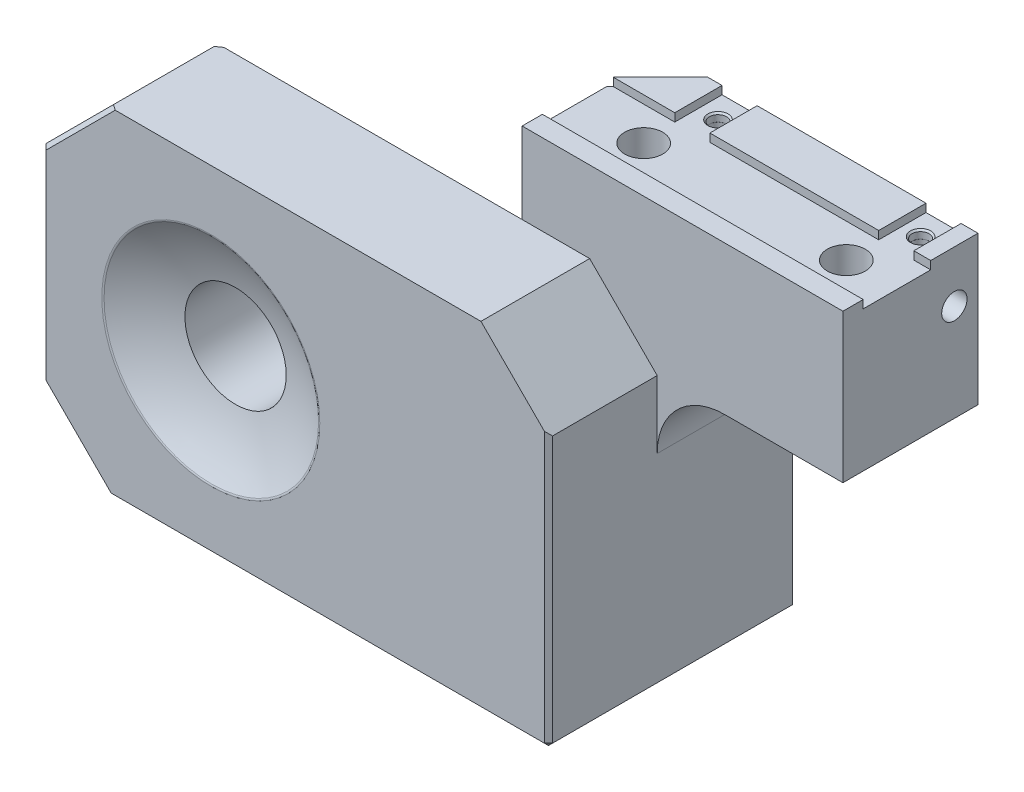
from build123d import *

# Parameters (mm, degrees)
SKETCH1_W                          = 25.4
SKETCH1_H                          = 76.2
EXTRUDE1_DEPTH                     = 20.447
SKETCH60_W                         = 25.4
SKETCH60_H                         = 63.5
EXTRUDE6_DEPTH                     = 63.5
SKETCH69_W                         = 63.5
SKETCH69_H                         = 63.5
SKETCH69_R                         = 22.225
CUT_EXTRUDE23_DEPTH                = 4.953
SKETCH71_R                         = 9.525
CUT_EXTRUDE24_DEPTH                = 78.776949699
SKETCH80_W                         = 20.447
SKETCH80_H                         = 76.2
EXTRUDE11_DEPTH                    = 6.35
SKETCH76_W                         = 25.4
SKETCH76_H                         = 76.2
EXTRUDE9_DEPTH                     = 25.4
SKETCH79_W                         = 50.8
SKETCH79_H                         = 6.35
EXTRUDE10_DEPTH                    = 88.096540741
SKETCH84_W                         = 60.325
SKETCH84_H                         = 25.4
EXTRUDE14_DEPTH                    = 15.24
EXTRUDE14_DEPTH_BACK               = 12.7
EXTRUDE15_DEPTH                    = 1.524
CBORE_FOR_1_8_PRESS_PIN_AT_2_COUNT = 2
CBORE_FOR_1_8_PRESS_PIN_AT_2_PITCH = 38.1
CHAMFER5_SIZE                      = 9.525
FILLET6_R                          = 12.7
CHAMFER3_SIZE                      = 12.7
FILLET7_R                          = 0.254
CHAMFER4_SIZE                      = 0.762
FILLET4_R                          = 2.54
FILLET5_R                          = 0.635
F_3_16_0_1875_DIAMETER_HOLE1_D     = 4.7625


with BuildPart() as part:
    # Sketch1 → Extrude1 (new body)
    with BuildSketch(Plane.XY):
        with Locations((12.7, 0)):
            Rectangle(SKETCH1_W, SKETCH1_H)
    extrude(amount=EXTRUDE1_DEPTH)

    # Sketch60 → Extrude6 (add)
    with BuildSketch(Plane.ZY):
        with Locations((7.747, 0)):
            Rectangle(SKETCH60_W, SKETCH60_H)
    extrude(amount=EXTRUDE6_DEPTH)

    # Sketch64 → Cut-Revolve1 (revolve, cut)
    with BuildSketch(Plane(origin=(0, 0, 0), x_dir=(-1, 0, 0), z_dir=(0, 1, 0))):
        with BuildLine():
            Line((9.525, -4.953), (9.525, 0.012163278))
            ThreePointArc((9.525, 0.012163278), (14.839678796, -1.926851671), (20.32, -3.331013047))
            Line((20.32, -3.331013047), (31.75, -3.331013047))
            Line((31.75, -3.331013047), (31.75, -4.953))
            Line((31.75, -4.953), (9.525, -4.953))
        make_face()
        with BuildLine():
            Line((31.75, 20.447), (11.43, 20.447))
            ThreePointArc((11.43, 20.447), (21.174424434, 16.073156441), (31.75, 14.575986953))
            Line((31.75, 14.575986953), (31.75, 20.447))
        make_face()
    revolve(axis=Axis((-31.75, 0, 14.575986953), (0, 0, 1)), mode=Mode.SUBTRACT)

    # Sketch69 → Cut-Extrude23 (cut)
    with BuildSketch(Plane(origin=(0, 0, -4.953), x_dir=(-1, 0, 0), z_dir=(0, 0, -1))):
        with Locations((31.75, 0)):
            Rectangle(SKETCH69_W, SKETCH69_H)
        with Locations(Location((31.75, 0, 0), (0, 0, 90))):
            Circle(SKETCH69_R, mode=Mode.SUBTRACT)
    extrude(amount=-CUT_EXTRUDE23_DEPTH, mode=Mode.SUBTRACT)

    # Sketch71 → Cut-Extrude24 (cut, through all)
    with BuildSketch(Plane.XY.offset(20.447)):
        with Locations((-31.75, 0)):
            Circle(SKETCH71_R)
    extrude(amount=-CUT_EXTRUDE24_DEPTH, mode=Mode.SUBTRACT)

    # Sketch80 → Extrude11 (add)
    with BuildSketch(Plane(origin=(25.4, 0, 0), x_dir=(0, 0, -1), z_dir=(1, 0, 0))):
        with Locations((-10.2235, 0)):
            Rectangle(SKETCH80_W, SKETCH80_H)
    extrude(amount=EXTRUDE11_DEPTH)

    # Sketch76 → Extrude9 (add)
    with BuildSketch(Plane(origin=(0, 0, 0), x_dir=(-1, 0, 0), z_dir=(0, 0, -1))):
        with Locations((-19.05, 0)):
            Rectangle(SKETCH76_W, SKETCH76_H)
    extrude(amount=EXTRUDE9_DEPTH)

    # Sketch79 → Extrude10 (cut, through all)
    with BuildSketch(Plane.XY.offset(20.447)):
        with Locations((6.35, -34.925)):
            Rectangle(SKETCH79_W, SKETCH79_H)
        with Locations((6.35, 34.925)):
            Rectangle(SKETCH79_W, SKETCH79_H)
    extrude(amount=-EXTRUDE10_DEPTH, mode=Mode.SUBTRACT)

    # Sketch84 → Extrude14 (add, two sides)
    with BuildSketch(Plane(origin=(0, 31.75, 0), x_dir=(1, 0, 0), z_dir=(0, 1, 0))) as extrude14_sk:
        with Locations((36.5125, 12.7)):
            Rectangle(SKETCH84_W, SKETCH84_H)
    extrude(amount=EXTRUDE14_DEPTH)
    extrude(extrude14_sk.sketch, amount=-EXTRUDE14_DEPTH_BACK)

    # Sketch85 → CBORE for 1_4 Socket Head Cap Screw1 (revolve, cut)
    with BuildSketch(Plane(origin=(19.05, -31.75, -10.16), x_dir=(0, 0, -1), z_dir=(1, 0, 0))):
        Polygon((0, 0), (0, 78.74), (4.20624, 78.74), (3.57124, 78.105), (3.57124, 50.8), (6.35, 50.8), (6.35, 0.762), (7.112, 0), align=None)
    revolve(axis=Axis((19.05, -38.1, -10.16), (0, 1, 0)), mode=Mode.SUBTRACT)

    # Sketch87 → 1_4 Clearance Hole2 (revolve, cut)
    with BuildSketch(Plane(origin=(57.15, 19.05, -10.16), x_dir=(0, 0, -1), z_dir=(1, 0, 0))):
        Polygon((0, 0), (0, 27.94), (4.20624, 27.94), (3.57124, 27.305), (3.57124, 0), align=None)
    revolve(axis=Axis((57.15, 12.7, -10.16), (0, 1, 0)), mode=Mode.SUBTRACT)

    # Sketch89 → Extrude15 (cut)
    with BuildSketch(Plane(origin=(0, 46.99, 0), x_dir=(1, 0, 0), z_dir=(0, 1, 0))):
        Polygon((6.35, 3.81), (66.675, 3.81), (66.675, 16.51), (63.5, 16.51), (63.5, 25.4), (56.896, 25.4), (56.896, 16.51), (25.146, 16.51), (25.146, 25.4), (18.542, 25.4), (18.542, 16.51), (6.35, 16.51), align=None)
    extrude(amount=-EXTRUDE15_DEPTH, mode=Mode.SUBTRACT)

    # Sketch90 → CBORE for 1_8_ Press Pin (revolve, cut)
    with BuildSketch(Plane(origin=(22.225, 45.466, -20.955), x_dir=(0, 0, 1), z_dir=(1, 0, 0))):
        Polygon((0, 0), (0, 7.303866233), (1.5875, 6.35), (1.5875, 1.524), (1.6002, 1.524), (1.6002, 0.3048), (1.905, 0), align=None)
    cbore_for_1_8_press_pin = revolve(axis=Axis((22.225, 51.816, -20.955), (0, -1, 0)), mode=Mode.SUBTRACT)

    # CBORE for 1_8_ Press Pin at 2: CBORE for 1_8_ Press Pin ×2
    with Locations(*[(i * CBORE_FOR_1_8_PRESS_PIN_AT_2_PITCH, 0, 0) for i in range(1, CBORE_FOR_1_8_PRESS_PIN_AT_2_COUNT)]):
        add(cbore_for_1_8_press_pin, mode=Mode.SUBTRACT)

    # Chamfer5
    chamfer5_edges = [part.edges().sort_by_distance(p)[0] for p in [
        (6.35, 7.62, -25.4),
    ]]
    chamfer(chamfer5_edges, length=CHAMFER5_SIZE)

    # Fillet6
    fillet6_edges = [part.edges().sort_by_distance(p)[0] for p in [
        (31.75, 19.05, -12.7),
    ]]
    fillet(fillet6_edges, radius=FILLET6_R)

    # Chamfer3
    chamfer3_edges = [part.edges().sort_by_distance(p)[0] for p in [
        (-63.5, 31.75, 10.2235),
        (-63.5, -31.75, 10.2235),
        (31.75, 31.75, 10.2235),
    ]]
    chamfer(chamfer3_edges, length=CHAMFER3_SIZE)

    # Fillet7
    fillet7_edges = [part.edges().sort_by_distance(p)[0] for p in [
        (6.35, 0, 0),
    ]]
    fillet(fillet7_edges, radius=FILLET7_R)

    # Chamfer4
    chamfer4_edges = [part.edges().sort_by_distance(p)[0] for p in [
        (23.8125, -31.75, -25.4),
        (-9.525, -31.75, 20.447),
        (31.75, -6.35, 20.447),
        (31.75, -31.75, -2.4765),
        (-22.352, -31.75, 0),
        (6.275605122, -31.75, -0.074394878),
        (6.35, -31.75, -8.0645),
        (-57.15, 25.4, 0),
        (-57.15, -25.4, 0),
        (-63.5, 0, 0),
        (-57.15, 25.4, 20.447),
        (-63.5, 0, 20.447),
        (-57.15, -25.4, 20.447),
        (11.1125, -31.75, -20.6375),
    ]]
    chamfer(chamfer4_edges, length=CHAMFER4_SIZE)

    # Fillet4
    fillet4_edges = [part.edges().sort_by_distance(p)[0] for p in [
        (-43.18, 0, -3.331013047),
    ]]
    fillet(fillet4_edges, radius=FILLET4_R)

    # Fillet5
    fillet5_edges = [part.edges().sort_by_distance(p)[0] for p in [
        (-52.07, 0, 20.447),
    ]]
    fillet(fillet5_edges, radius=FILLET5_R)

    # 3_16 _0.1875_ Diameter Hole1 (through all)
    with Locations(Plane(origin=(66.675, 0, 0), x_dir=(0, 0, -1), z_dir=(1, 0, 0))):
        with Locations((20.955, 37.338)):
            Hole(F_3_16_0_1875_DIAMETER_HOLE1_D / 2)


solid = part.part
